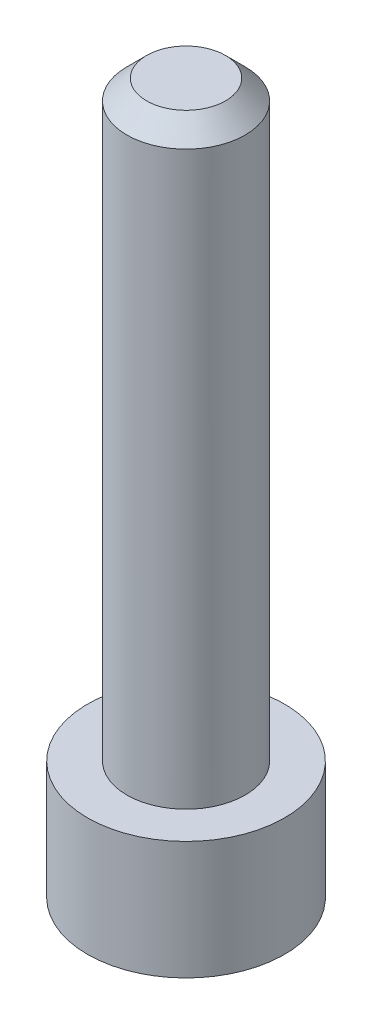
from build123d import *

# Parameters (mm, degrees)
CHANFREIN1_SIZE = 0.5


with BuildPart() as part:
    # Esquisse1 → Révolution1 (revolve)
    with BuildSketch(Plane.XY):
        Polygon((0, 0), (1.5, 0), (1.5, -15), (2.5, -15), (2.5, -18), (0, -18), align=None)
    revolve(axis=Axis((0, 0, 0), (0, -1, 0)))

    # Chanfrein1
    chanfrein1_edges = [part.edges().sort_by_distance(p)[0] for p in [
        (-1.5, 0, 0),
    ]]
    chamfer(chanfrein1_edges, length=CHANFREIN1_SIZE)


solid = part.part
